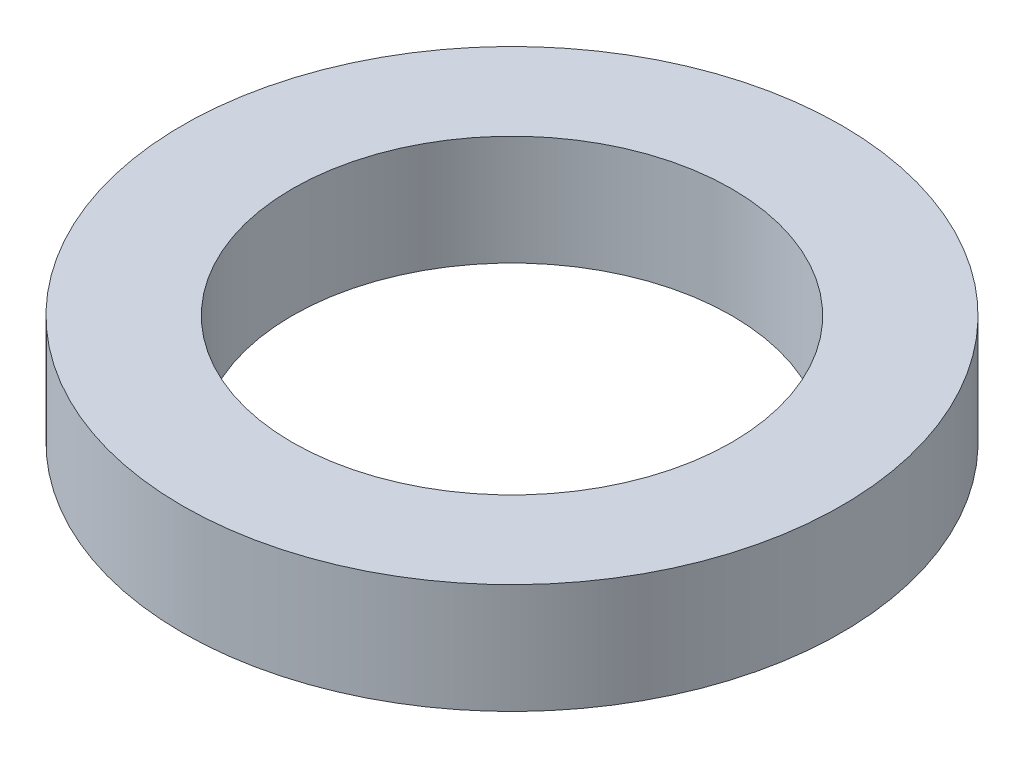
from build123d import *

# Parameters (mm, degrees)
SKETCH1_R           = 9.525
BOSS_EXTRUDE1_DEPTH = 3.175
SKETCH5_R           = 6.35
CUT_EXTRUDE1_DEPTH  = 4.175


with BuildPart() as part:
    # Sketch1 → Boss-Extrude1 (new body)
    with BuildSketch(Plane(origin=(0, 0, 0), x_dir=(1, 0, 0), z_dir=(0, 1, 0))):
        Circle(SKETCH1_R)
    extrude(amount=BOSS_EXTRUDE1_DEPTH)

    # Sketch5 → Cut-Extrude1 (cut, through all)
    with BuildSketch(Plane(origin=(0, 3.175, 0), x_dir=(-1, 0, 0), z_dir=(0, 1, 0))):
        Circle(SKETCH5_R)
    extrude(amount=-CUT_EXTRUDE1_DEPTH, mode=Mode.SUBTRACT)


solid = part.part
